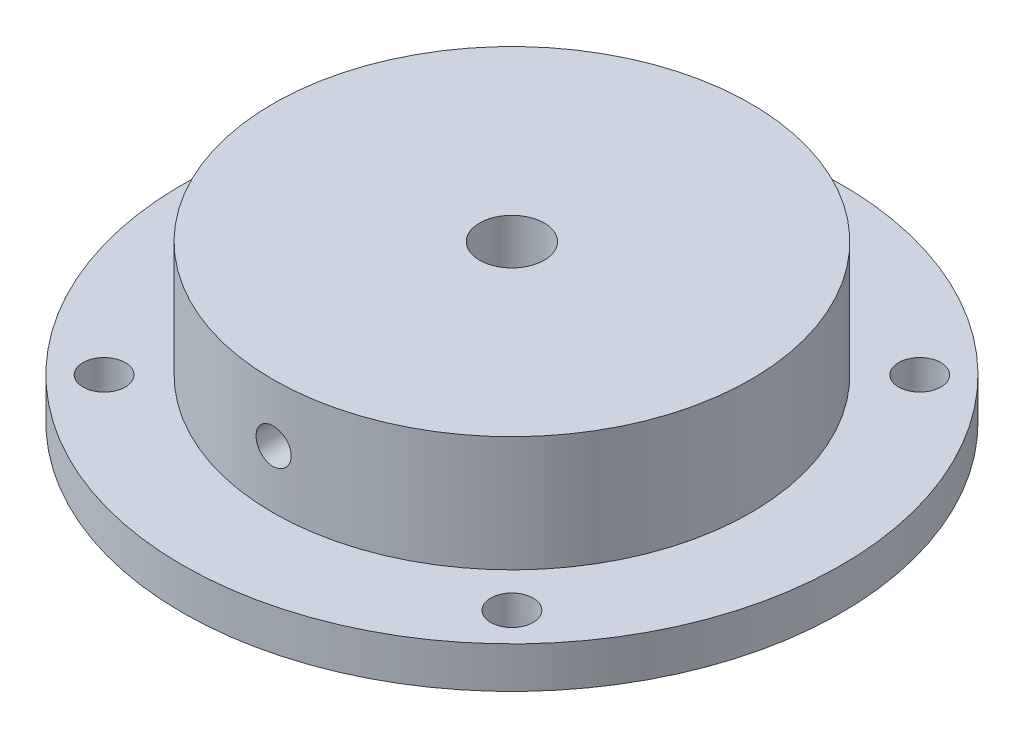
from build123d import *

# Parameters (mm, degrees)
SKETCH10_R                 = 25.4
BOSS_EXTRUDE1_DEPTH        = 3.175
SKETCH13_R                 = 18.415
BOSS_EXTRUDE2_DEPTH        = 8.89
F_9_0_196_DIAMETER_HOLE1_D = 4.9784
SKETCH18_W                 = 1.35255
SKETCH18_H                 = 25.4
F_4_CLEARANCE_HOLE2_D      = 3.2639
F_4_CLEARANCE_HOLE2_DEPTH  = 3.302
F_4_CLEARANCE_HOLE2_TIP    = 0.980574487


with BuildPart() as part:
    # Sketch10 → Boss-Extrude1 (new body)
    with BuildSketch(Plane(origin=(0, 0, 0), x_dir=(1, 0, 0), z_dir=(0, 1, 0))):
        Circle(SKETCH10_R)
    extrude(amount=BOSS_EXTRUDE1_DEPTH)

    # Sketch13 → Boss-Extrude2 (add)
    with BuildSketch(Plane(origin=(0, 3.175, 0), x_dir=(1, 0, 0), z_dir=(0, 1, 0))):
        Circle(SKETCH13_R)
    extrude(amount=BOSS_EXTRUDE2_DEPTH)

    # #9 (0.196) Diameter Hole1 (through all)
    with Locations(Plane(origin=(0, 12.065, 0), x_dir=(1, 0, 0), z_dir=(0, 1, 0))):
        with Locations((0, 0)):
            Hole(F_9_0_196_DIAMETER_HOLE1_D / 2)

    # Sketch18 → #6-32 Tapped Hole2 (revolve, cut)
    with BuildSketch(Plane(origin=(0, 7.62, 0), x_dir=(0, 1, 0), z_dir=(1, 0, 0))):
        with Locations((0.676275, 12.7)):
            Rectangle(SKETCH18_W, SKETCH18_H)
    revolve(axis=Axis((0, 7.62, -6.35), (0, 0, 1)), mode=Mode.SUBTRACT)

    # #4 Clearance Hole2
    with Locations(Plane(origin=(0, 0, 0), x_dir=(-1, 0, 0), z_dir=(0, -1, 0))):
        with Locations((-15.715448212, -15.715448212), (15.715448212, -15.715448212), (15.715448212, 15.715448212), (-15.715448212, 15.715448212)):
            Hole(F_4_CLEARANCE_HOLE2_D / 2, depth=F_4_CLEARANCE_HOLE2_DEPTH)
            with Locations((0, 0, -(F_4_CLEARANCE_HOLE2_DEPTH + F_4_CLEARANCE_HOLE2_TIP / 2))):  # 118° drill point
                Cone(0, F_4_CLEARANCE_HOLE2_D / 2, F_4_CLEARANCE_HOLE2_TIP, mode=Mode.SUBTRACT)


solid = part.part
